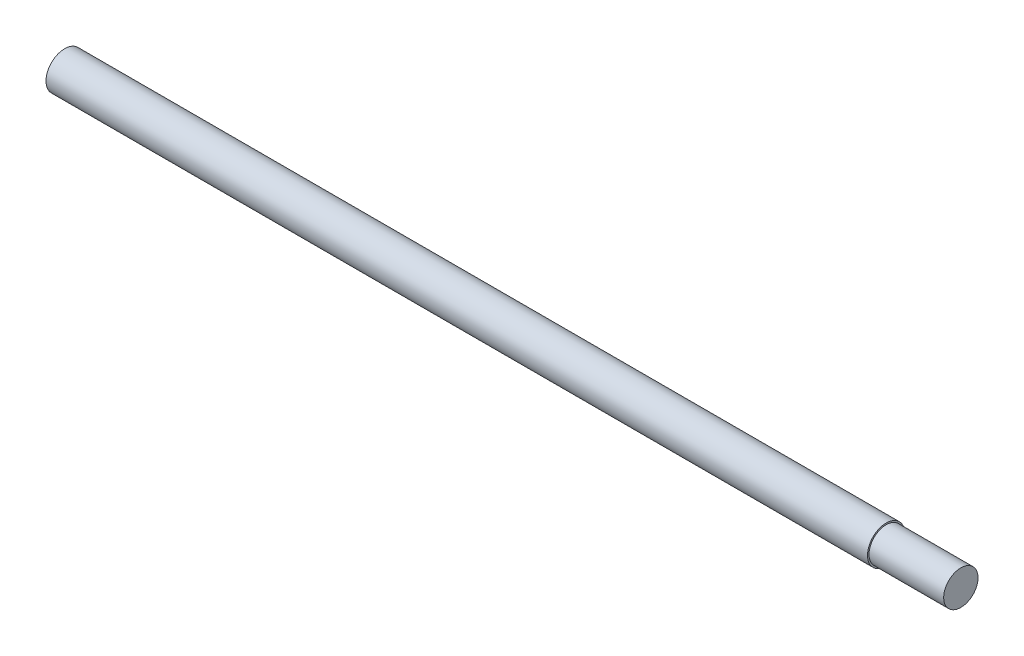
from build123d import *


with BuildPart() as part:
    # Sketch1 → Revolve1 (revolve)
    with BuildSketch(Plane(origin=(0, 0, 0), x_dir=(1, 0, 0), z_dir=(0, 1, 0))):
        Polygon((57.435652368, -3.655929787), (57.435652368, -5.955929787), (47.435652368, -5.955929787), (47.435652368, -6.155929787), (-62.564347632, -6.155929787), (-62.564347632, -3.655929787), align=None)
    revolve(axis=Axis((-62.564347632, 0, 3.655929787), (1, 0, 0)))


solid = part.part
